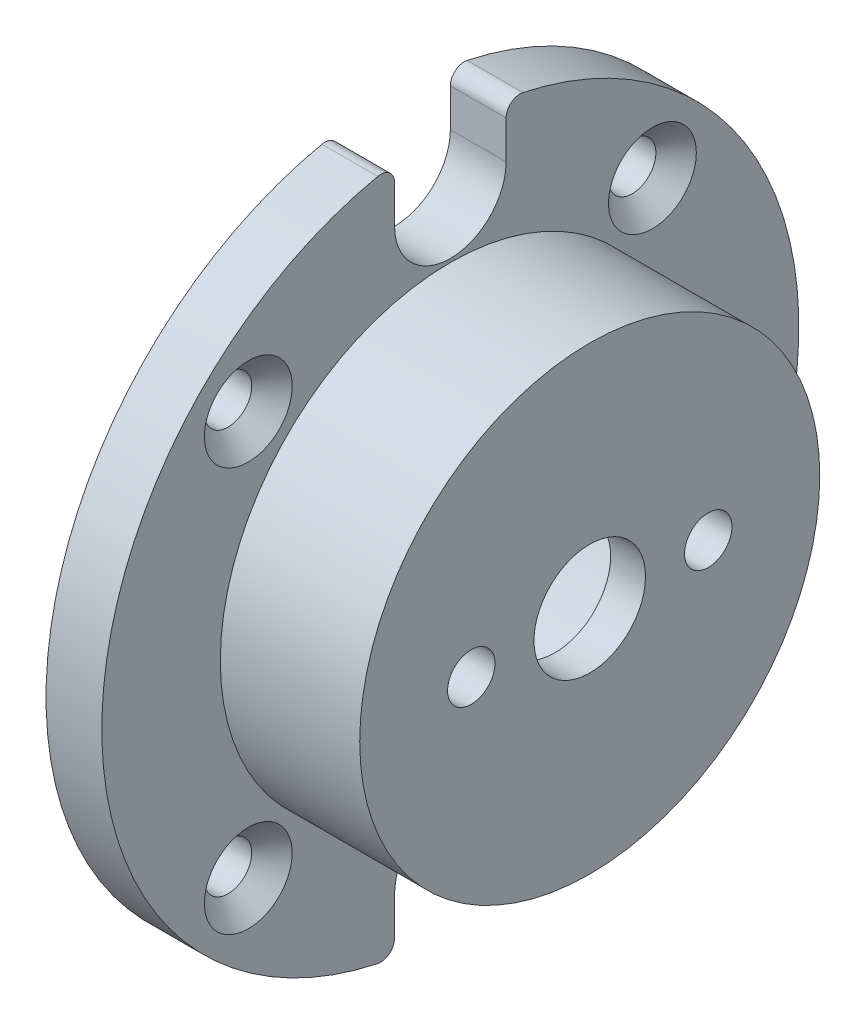
from build123d import *

# Parameters (mm, degrees)
SKETCH1_R                                       = 25
BOSS_EXTRUDE1_DEPTH                             = 4
SKETCH2_R                                       = 16.5
BOSS_EXTRUDE2_DEPTH                             = 10
SKETCH3_R                                       = 12.5
CUT_EXTRUDE1_DEPTH                              = 11.5
SKETCH4_R                                       = 4
CUT_EXTRUDE2_DEPTH                              = 4
M3_CLEARANCE_HOLE1_D                            = 3.4
M3_CLEARANCE_HOLE1_DEPTH                        = 10
CSK_FOR_M3_FLAT_HEAD_MACHINE_SCREW1_D           = 3.4
CSK_FOR_M3_FLAT_HEAD_MACHINE_SCREW1_CSINK_D     = 6.3
CSK_FOR_M3_FLAT_HEAD_MACHINE_SCREW1_CSINK_ANGLE = 90
CIRPATTERN1_COUNT                               = 4
SKETCH10_R                                      = 13.125
CUT_EXTRUDE3_DEPTH                              = 11.5
CUT_EXTRUDE4_DEPTH                              = 10


with BuildPart() as part:
    # Sketch1 → Boss-Extrude1 (new body)
    with BuildSketch(Plane(origin=(0, 0, 0), x_dir=(0, 0, -1), z_dir=(1, 0, 0))):
        Circle(SKETCH1_R)
    extrude(amount=BOSS_EXTRUDE1_DEPTH)

    # Sketch2 → Boss-Extrude2 (add)
    with BuildSketch(Plane(origin=(4, 0, 0), x_dir=(0, 0, -1), z_dir=(1, 0, 0))):
        Circle(SKETCH2_R)
    extrude(amount=BOSS_EXTRUDE2_DEPTH)

    # Sketch3 → Cut-Extrude1 (cut)
    with BuildSketch(Plane.ZY):
        Circle(SKETCH3_R)
    extrude(amount=-CUT_EXTRUDE1_DEPTH, mode=Mode.SUBTRACT)

    # Sketch4 → Cut-Extrude2 (cut)
    with BuildSketch(Plane(origin=(14, 0, 0), x_dir=(0, 0, -1), z_dir=(1, 0, 0))):
        Circle(SKETCH4_R)
    extrude(amount=-CUT_EXTRUDE2_DEPTH, mode=Mode.SUBTRACT)

    # M3 Clearance Hole1
    with Locations(Plane(origin=(14, 0, 0), x_dir=(0, 0, -1), z_dir=(1, 0, 0))):
        with Locations((8.5, 0), (-8.5, 0)):
            Hole(M3_CLEARANCE_HOLE1_D / 2, depth=M3_CLEARANCE_HOLE1_DEPTH)

    # CSK for M3 Flat Head Machine Screw1 (through all)
    with Locations(Plane(origin=(4, 0, 0), x_dir=(0, 0, -1), z_dir=(1, 0, 0))):
        with Locations((-14.495689014, -14.495689014)):
            csk_for_m3_flat_head_machine_screw1 = CounterSinkHole(CSK_FOR_M3_FLAT_HEAD_MACHINE_SCREW1_D / 2, CSK_FOR_M3_FLAT_HEAD_MACHINE_SCREW1_CSINK_D / 2, counter_sink_angle=CSK_FOR_M3_FLAT_HEAD_MACHINE_SCREW1_CSINK_ANGLE)

    # CirPattern1: CSK for M3 Flat Head Machine Screw1 ×4 about axis
    cirpattern1_axis = Axis((0, 0, 0), (1, 0, 0))
    for i in range(1, CIRPATTERN1_COUNT):
        add(csk_for_m3_flat_head_machine_screw1.rotate(cirpattern1_axis, i * 360 / CIRPATTERN1_COUNT), mode=Mode.SUBTRACT)

    # Sketch10 → Cut-Extrude3 (cut)
    with BuildSketch(Plane.ZY):
        Circle(SKETCH10_R)
    extrude(amount=-CUT_EXTRUDE3_DEPTH, mode=Mode.SUBTRACT)

    # Sketch12 → Cut-Extrude4 (cut)
    with BuildSketch(Plane(origin=(4, 0, 0), x_dir=(0, 0, -1), z_dir=(1, 0, 0))):
        with BuildLine():
            Line((-4, 20.75), (-4, 23.473389189))
            ThreePointArc((-4, 23.473389189), (-4.37084713, 24.250670776), (-5.208333333, 24.451447071))
            ThreePointArc((-5.208333333, 24.451447071), (0, 25), (5.208333333, 24.451447071))
            ThreePointArc((5.208333333, 24.451447071), (4.37084713, 24.250670776), (4, 23.473389189))
            Line((4, 23.473389189), (4, 20.75))
            ThreePointArc((4, 20.75), (0, 16.75), (-4, 20.75))
        make_face()
        with BuildLine():
            Line((4, -20.75), (4, -23.473389189))
            ThreePointArc((4, -23.473389189), (4.37084713, -24.250670776), (5.208333333, -24.451447071))
            ThreePointArc((5.208333333, -24.451447071), (0, -25), (-5.208333333, -24.451447071))
            ThreePointArc((-5.208333333, -24.451447071), (-4.37084713, -24.250670776), (-4, -23.473389189))
            Line((-4, -23.473389189), (-4, -20.75))
            ThreePointArc((-4, -20.75), (0, -16.75), (4, -20.75))
        make_face()
    extrude(amount=-CUT_EXTRUDE4_DEPTH, mode=Mode.SUBTRACT)


solid = part.part
